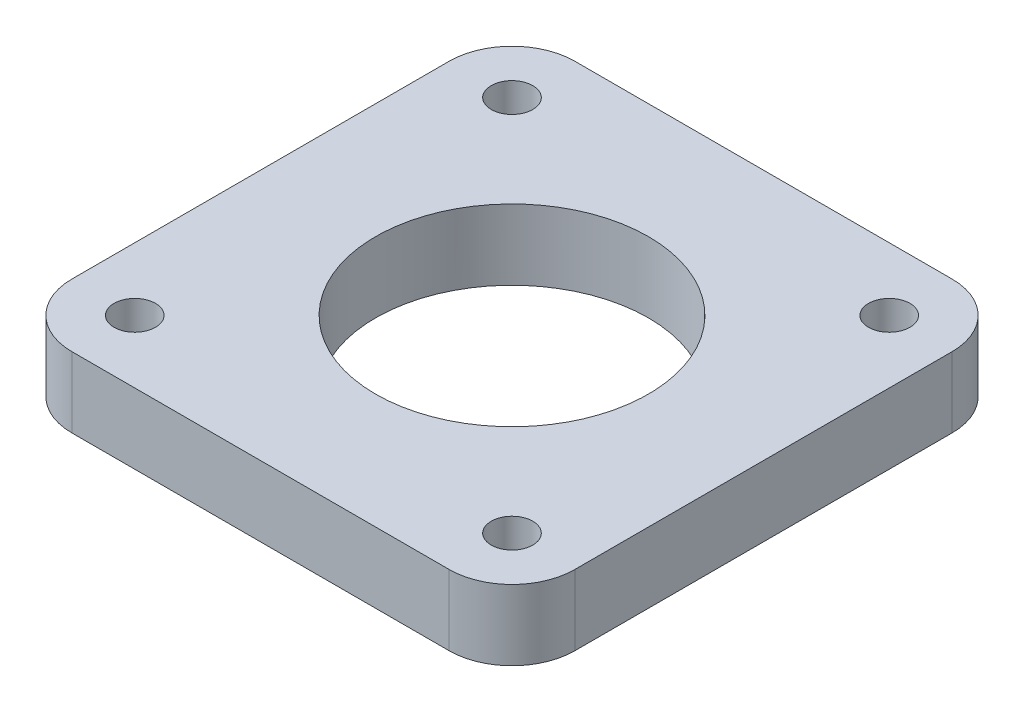
from build123d import *

# Parameters (mm, degrees)
BOSS_EXTRUDE1_DEPTH = 5.6
SKETCH3_R           = 10.85
CUT_EXTRUDE2_DEPTH  = 7.5
SKETCH5_R           = 1.65
CUT_EXTRUDE4_DEPTH  = 6.6


with BuildPart() as part:
    # Sketch1 → Boss-Extrude1 (new body)
    with BuildSketch(Plane(origin=(0, 0, 0), x_dir=(1, 0, 0), z_dir=(0, 1, 0))):
        with BuildLine():
            Line((-20, 15), (-20, -15))
            ThreePointArc((-20, -15), (-18.535533906, -18.535533906), (-15, -20))
            Line((-15, -20), (15, -20))
            ThreePointArc((15, -20), (18.535533906, -18.535533906), (20, -15))
            Line((20, -15), (20, 15))
            ThreePointArc((20, 15), (18.535533906, 18.535533906), (15, 20))
            Line((15, 20), (-15, 20))
            ThreePointArc((-15, 20), (-18.535533906, 18.535533906), (-20, 15))
        make_face()
    extrude(amount=BOSS_EXTRUDE1_DEPTH)

    # Sketch3 → Cut-Extrude2 (cut)
    with BuildSketch(Plane(origin=(0, 0, 0), x_dir=(-1, 0, 0), z_dir=(0, -1, 0))):
        Circle(SKETCH3_R)
    extrude(amount=-CUT_EXTRUDE2_DEPTH, mode=Mode.SUBTRACT)

    # Sketch5 → Cut-Extrude4 (cut, through all)
    with BuildSketch(Plane(origin=(0, 5.6, 0), x_dir=(1, 0, 0), z_dir=(0, 1, 0))):
        with Locations((-15, 15)):
            Circle(SKETCH5_R)
        with Locations((15, 15)):
            Circle(SKETCH5_R)
        with Locations((15, -15)):
            Circle(SKETCH5_R)
        with Locations((-15, -15)):
            Circle(SKETCH5_R)
    extrude(amount=-CUT_EXTRUDE4_DEPTH, mode=Mode.SUBTRACT)


solid = part.part
